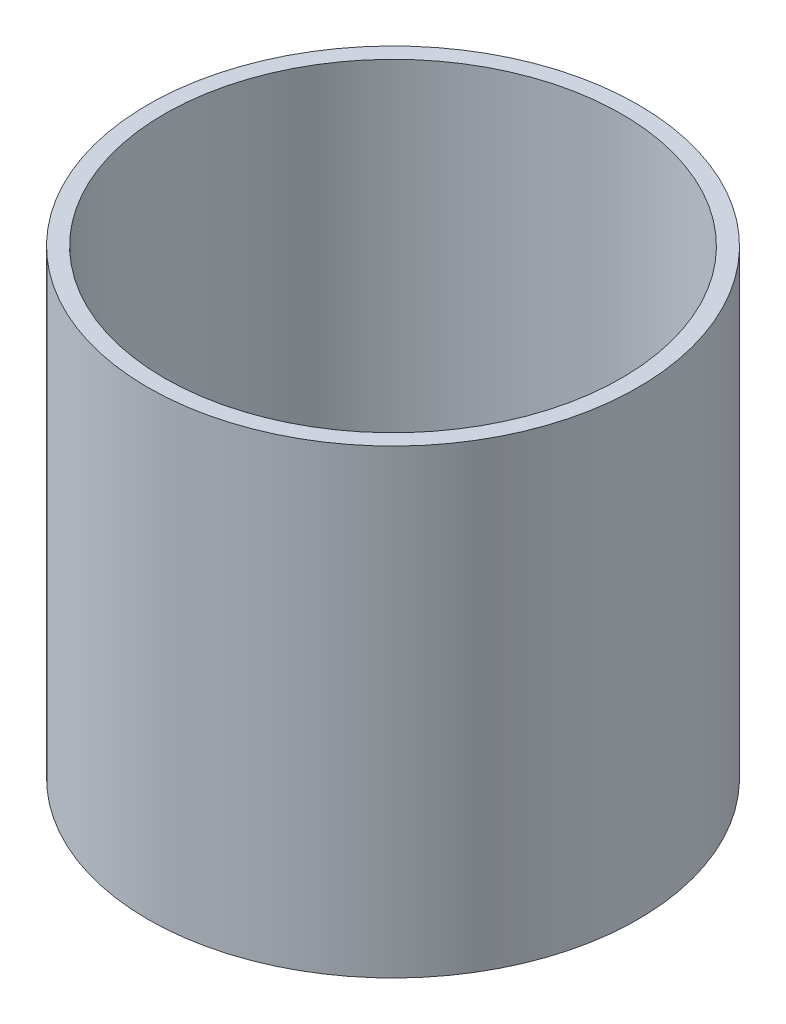
from build123d import *

# Parameters (mm, degrees)
BOSS_EXTRUDE1_DEPTH = 282


with BuildPart() as part:
    # Sketch2 → Boss-Extrude1 (new body)
    with BuildSketch(Plane(origin=(0, 0, 0), x_dir=(1, 0, 0), z_dir=(0, 1, 0))):
        with BuildLine():
            ThreePointArc((150, 0), (106.066017178, 106.066017178), (0, 150))
            Line((0, 150), (0, 140))
            ThreePointArc((0, 140), (98.994949366, 98.994949366), (140, 0))
            ThreePointArc((140, 0), (98.994949366, -98.994949366), (0, -140))
            Line((0, -140), (0, -150))
            ThreePointArc((0, -150), (106.066017178, -106.066017178), (150, 0))
        make_face()
        with BuildLine():
            Line((0, 140), (0, 150))
            ThreePointArc((0, 150), (-150, 0), (0, -150))
            Line((0, -150), (0, -140))
            ThreePointArc((0, -140), (-140, 0), (0, 140))
        make_face()
    extrude(amount=BOSS_EXTRUDE1_DEPTH)


solid = part.part
